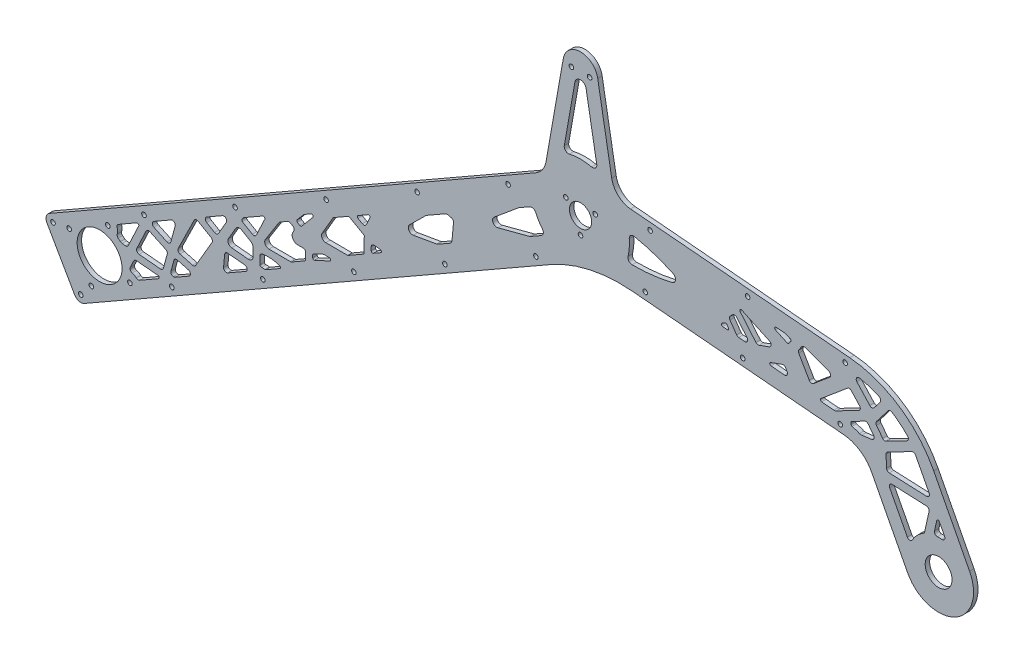
from build123d import *

# Parameters (mm, degrees)
SKETCH2_R              = 7.9375
SKETCH2_R_2            = 16.05
SKETCH2_R_3            = 1.65
SKETCH2_R_4            = 9.5885
BASE_DEPTH             = 3.175
SKETCH3_R              = 1.65
STRUT_HOLES_DEPTH      = 4.175
LIGHTENING_HOLES_DEPTH = 4.175
SKETCH7_R              = 1.65
CUT_EXTRUDE1_DEPTH     = 4.175


with BuildPart() as part:
    # Sketch2 → Base (new body)
    with BuildSketch(Plane.XY):
        with BuildLine():
            Line((-379.716809958, -188.506893436), (-32.006532147, 10.487277971))
            ThreePointArc((-32.006532147, 10.487277971), (-27.186230121, 14.879084252), (-24.685038782, 20.901319377))
            Line((-24.685038782, 20.901319377), (-12.310096913, 91.083102221))
            ThreePointArc((-12.310096913, 91.083102221), (0, 101.4125), (12.310096913, 91.083102221))
            Line((12.310096913, 91.083102221), (22.322003955, 34.302755831))
            ThreePointArc((22.322003955, 34.302755831), (26.960267136, 25.848318444), (35.786784109, 21.964558025))
            Line((35.786784109, 21.964558025), (192.586144941, 8.246391504))
            ThreePointArc((192.586144941, 8.246391504), (227.717231711, -4.10798993), (252.575276723, -31.83706486))
            Line((252.575276723, -31.83706486), (278.255270829, -81.167874559))
            ThreePointArc((278.255270829, -81.167874559), (267.623715331, -114.886860719), (233.904729171, -104.255305221))
            Line((233.904729171, -104.255305221), (208.224735064, -54.924495522))
            ThreePointArc((208.224735064, -54.924495522), (199.93872006, -45.681470545), (188.228357804, -41.563343401))
            Line((188.228357804, -41.563343401), (36.823729736, -28.317154839))
            ThreePointArc((36.823729736, -28.317154839), (6.649577682, -30.266109959), (-21.562664076, -41.144864173))
            Line((-21.562664076, -41.144864173), (-354.881400189, -231.902773674))
            ThreePointArc((-354.881400189, -231.902773674), (-358.677364619, -232.387866435), (-361.70452919, -230.046726627))
            Line((-361.70452919, -230.046726627), (-381.572857005, -195.330022437))
            ThreePointArc((-381.572857005, -195.330022437), (-382.057949767, -191.534058007), (-379.716809958, -188.506893436))
        make_face()
        Circle(SKETCH2_R, mode=Mode.SUBTRACT)
        with Locations((-343.92, -196.825)):
            Circle(SKETCH2_R_2, mode=Mode.SUBTRACT)
        with Locations((-6.5, 88.9125)):
            Circle(SKETCH2_R_3, mode=Mode.SUBTRACT)
        with Locations((6.5, 88.9125)):
            Circle(SKETCH2_R_3, mode=Mode.SUBTRACT)
        with Locations((256.08, -92.71158989)):
            Circle(SKETCH2_R_4, mode=Mode.SUBTRACT)
        with Locations((-365.631063534, -190.919094461)):
            Circle(SKETCH2_R_3, mode=Mode.SUBTRACT)
        with Locations((-338.014094461, -175.113936466)):
            Circle(SKETCH2_R_3, mode=Mode.SUBTRACT)
        with Locations((-322.208936466, -202.730905539)):
            Circle(SKETCH2_R_3, mode=Mode.SUBTRACT)
        with Locations((-349.825905539, -218.536063534)):
            Circle(SKETCH2_R_3, mode=Mode.SUBTRACT)
    extrude(amount=BASE_DEPTH)

    # Sketch3 → Strut Holes (cut, through all)
    with BuildSketch(Plane.XY.offset(3.175)):
        with Locations((-357.364941166, -227.56318565)):
            Circle(SKETCH3_R)
        with Locations((-292.27112081, -190.310070996)):
            Circle(SKETCH3_R)
        with Locations((-227.177300453, -153.056956343)):
            Circle(SKETCH3_R)
        with Locations((-162.083480097, -115.803841689)):
            Circle(SKETCH3_R)
        with Locations((-96.98965974, -78.550727035)):
            Circle(SKETCH3_R)
        with Locations((-31.895839384, -41.297612382)):
            Circle(SKETCH3_R)
        with Locations((-312.139448625, -155.593366806)):
            Circle(SKETCH3_R)
        with Locations((-377.233268981, -192.84648146)):
            Circle(SKETCH3_R)
        with Locations((-247.045628268, -118.340252152)):
            Circle(SKETCH3_R)
        with Locations((-181.951807912, -81.087137499)):
            Circle(SKETCH3_R)
        with Locations((-116.857987555, -43.834022845)):
            Circle(SKETCH3_R)
        with Locations((-51.764167199, -6.580908192)):
            Circle(SKETCH3_R)
        with Locations((46.269308527, -24.124436716)):
            Circle(SKETCH3_R)
        with Locations((116.002937393, -30.225338708)):
            Circle(SKETCH3_R)
        with Locations((185.73656626, -36.326240701)):
            Circle(SKETCH3_R)
        with Locations((189.222795969, 3.521547223)):
            Circle(SKETCH3_R)
        with Locations((119.489167103, 9.622449215)):
            Circle(SKETCH3_R)
        with Locations((49.755538237, 15.723351208)):
            Circle(SKETCH3_R)
    extrude(amount=-STRUT_HOLES_DEPTH, mode=Mode.SUBTRACT)

    # Sketch6 → Lightening Holes (cut, through all)
    with BuildSketch(Plane.XY.offset(3.175)):
        with BuildLine():
            Line((-315.269185897, -197.710920307), (-301.759255291, -189.979203363))
            ThreePointArc((-301.759255291, -189.979203363), (-301.27885272, -188.89855459), (-302.165025934, -188.115429161))
            Line((-302.165025934, -188.115429161), (-317.529091672, -186.71244549))
            ThreePointArc((-317.529091672, -186.71244549), (-318.704383169, -186.968323474), (-319.520360019, -187.852045956))
            Line((-319.520360019, -187.852045956), (-321.920665487, -192.94890269))
            ThreePointArc((-321.920665487, -192.94890269), (-322.086706026, -193.488507205), (-322.095332893, -194.053014132))
            ThreePointArc((-322.095332893, -194.053014132), (-322.08483495, -194.136958475), (-322.074659882, -194.220942566))
            ThreePointArc((-322.074659882, -194.220942566), (-321.584640098, -195.311697425), (-320.559879114, -195.927920176))
            ThreePointArc((-320.559879114, -195.927920176), (-318.977814459, -196.521247692), (-317.584009883, -197.476378529))
            ThreePointArc((-317.584009883, -197.476378529), (-316.464213346, -197.964897395), (-315.269185897, -197.710920307))
        make_face()
        with BuildLine():
            Line((-289.844978396, -183.160677107), (-279.93882887, -177.491399715))
            ThreePointArc((-279.93882887, -177.491399715), (-278.948378644, -175.502042811), (-280.407275879, -173.825692191))
            Line((-280.407275879, -173.825692191), (-288.292322007, -171.680779414))
            ThreePointArc((-288.292322007, -171.680779414), (-289.810707779, -171.874816518), (-290.747163702, -173.085682346))
            Line((-290.747163702, -173.085682346), (-292.868560549, -180.884280112))
            ThreePointArc((-292.868560549, -180.884280112), (-292.613471256, -182.502456625), (-291.234784363, -183.387209827))
            ThreePointArc((-291.234784363, -183.387209827), (-291.195764259, -183.393163574), (-291.156778347, -183.399337252))
            ThreePointArc((-291.156778347, -183.399337252), (-290.480404568, -183.392541824), (-289.844978396, -183.160677107))
        make_face()
        with BuildLine():
            Line((-225.068253149, -146.0890356), (-215.065938543, -140.36472305))
            ThreePointArc((-215.065938543, -140.36472305), (-214.567033215, -139.40324417), (-215.236329185, -138.55154524))
            ThreePointArc((-215.236329185, -138.55154524), (-221.331874052, -137.268264968), (-227.555460503, -137.531793255))
            ThreePointArc((-227.555460503, -137.531793255), (-228.747493021, -138.209832448), (-229.222550686, -139.49630005))
            Line((-229.222550686, -139.49630005), (-229.243920799, -145.124584195))
            ThreePointArc((-229.243920799, -145.124584195), (-228.903638362, -145.87990104), (-228.110599563, -146.11945299))
            ThreePointArc((-228.110599563, -146.11945299), (-226.935128796, -146.061146676), (-225.766503733, -146.200597789))
            ThreePointArc((-225.766503733, -146.200597789), (-225.407188584, -146.208593442), (-225.068253149, -146.0890356))
        make_face()
        with BuildLine():
            Line((-202.41887229, -105.511400104), (-200.686234771, -106.520529682))
            ThreePointArc((-200.686234771, -106.520529682), (-200.013042452, -106.64186894), (-199.419351845, -106.302100524))
            Line((-199.419351845, -106.302100524), (-191.360868047, -96.772094027))
            ThreePointArc((-191.360868047, -96.772094027), (-191.355986863, -95.486528074), (-192.621174572, -95.258484862))
            Line((-192.621174572, -95.258484862), (-197.478989202, -98.038606299))
            ThreePointArc((-197.478989202, -98.038606299), (-197.765321596, -98.237482482), (-198.01276947, -98.483058387))
            Line((-198.01276947, -98.483058387), (-202.679186023, -104.001587826))
            ThreePointArc((-202.679186023, -104.001587826), (-202.901047671, -104.817187109), (-202.41887229, -105.511400104))
        make_face()
        with BuildLine():
            Line((-330.425499061, -170.667183769), (-317.378257487, -163.200263197))
            ThreePointArc((-317.378257487, -163.200263197), (-316.203164595, -163.333473919), (-315.976852671, -164.494237166))
            Line((-315.976852671, -164.494237166), (-323.402158767, -180.26128093))
            ThreePointArc((-323.402158767, -180.26128093), (-324.218135617, -181.145003412), (-325.393427114, -181.400881396))
            Line((-325.393427114, -181.400881396), (-327.826064744, -181.178742873))
            ThreePointArc((-327.826064744, -181.178742873), (-328.456346912, -181.014705953), (-329.000507167, -180.656860539))
            ThreePointArc((-329.000507167, -180.656860539), (-329.788551481, -179.963737807), (-330.608754561, -179.308986045))
            ThreePointArc((-330.608754561, -179.308986045), (-331.300981929, -178.333954341), (-331.313186478, -177.138246768))
            ThreePointArc((-331.313186478, -177.138246768), (-331.014233087, -175.069882607), (-331.339196402, -173.005445087))
            ThreePointArc((-331.339196402, -173.005445087), (-331.294912573, -171.675100882), (-330.425499061, -170.667183769))
        make_face()
        with BuildLine():
            Line((-295.53330948, -171.631597975), (-298.296173769, -181.788333758))
            ThreePointArc((-298.296173769, -181.788333758), (-299.085121934, -182.906012266), (-300.407921189, -183.255077571))
            Line((-300.407921189, -183.255077571), (-315.662540801, -181.862088072))
            ThreePointArc((-315.662540801, -181.862088072), (-317.216500905, -180.86379127), (-317.290058936, -179.018262152))
            Line((-317.290058936, -179.018262152), (-310.641451377, -164.900475625))
            ThreePointArc((-310.641451377, -164.900475625), (-309.508957679, -163.870619434), (-307.979945409, -163.943195111))
            Line((-307.979945409, -163.943195111), (-296.611069066, -169.297235353))
            ThreePointArc((-296.611069066, -169.297235353), (-295.647370018, -170.26828046), (-295.53330948, -171.631597975))
        make_face()
        with BuildLine():
            Line((-292.778723285, -149.121979529), (-305.215642876, -156.239613568))
            ThreePointArc((-305.215642876, -156.239613568), (-306.220639762, -158.055100377), (-305.074339213, -159.784842018))
            Line((-305.074339213, -159.784842018), (-295.766029178, -164.168482495))
            ThreePointArc((-295.766029178, -164.168482495), (-294.075568316, -164.17490103), (-292.984044137, -162.884058635))
            Line((-292.984044137, -162.884058635), (-289.85543458, -151.38278412))
            ThreePointArc((-289.85543458, -151.38278412), (-290.561768266, -149.275742292), (-292.778723285, -149.121979529))
        make_face()
        with BuildLine():
            Line((-286.412158457, -167.010536912), (-277.477694151, -169.440915421))
            ThreePointArc((-277.477694151, -169.440915421), (-276.194379154, -169.361694864), (-275.224483334, -168.5176123))
            Line((-275.224483334, -168.5176123), (-263.487039881, -148.364863469))
            ThreePointArc((-263.487039881, -148.364863469), (-263.281478176, -146.847994939), (-264.208712124, -145.63005284))
            Line((-264.208712124, -145.63005284), (-273.491108909, -140.223762697))
            ThreePointArc((-273.491108909, -140.223762697), (-275.075155334, -140.037188202), (-276.291924346, -141.06844292))
            Line((-276.291924346, -141.06844292), (-287.68143532, -164.197103385))
            ThreePointArc((-287.68143532, -164.197103385), (-287.710247586, -165.903135064), (-286.412158457, -167.010536912))
        make_face()
        with BuildLine():
            Line((-267.326941544, -134.555955625), (-255.981699002, -128.063087041))
            ThreePointArc((-255.981699002, -128.063087041), (-253.568709634, -128.390088491), (-253.260041176, -130.805491443))
            Line((-253.260041176, -130.805491443), (-258.957478514, -140.587777008))
            ThreePointArc((-258.957478514, -140.587777008), (-260.175420613, -141.515010956), (-261.692289142, -141.309449251))
            Line((-261.692289142, -141.309449251), (-267.340094346, -138.02003227))
            ThreePointArc((-267.340094346, -138.02003227), (-268.333510737, -136.284197061), (-267.326941544, -134.555955625))
        make_face()
        with BuildLine():
            Line((-255.261313261, -159.742391016), (-254.488576255, -151.280152708))
            ThreePointArc((-254.488576255, -151.280152708), (-253.776611846, -149.925068788), (-252.314987955, -149.470314621))
            Line((-252.314987955, -149.470314621), (-240.229659184, -150.573897437))
            ThreePointArc((-240.229659184, -150.573897437), (-238.457312757, -152.140148294), (-239.418117899, -154.30144584))
            Line((-239.418117899, -154.30144584), (-252.276183677, -161.660101332))
            ThreePointArc((-252.276183677, -161.660101332), (-254.350596062, -161.606956723), (-255.261313261, -159.742391016))
        make_face()
        with BuildLine():
            Line((-246.540160509, -131.189393308), (-251.794794147, -140.211401578))
            ThreePointArc((-251.794794147, -140.211401578), (-251.868704934, -143.096387582), (-249.475244653, -144.708825158))
            Line((-249.475244653, -144.708825158), (-237.508018237, -145.801623349))
            ThreePointArc((-237.508018237, -145.801623349), (-235.21684764, -145.033565045), (-234.235227202, -142.825444219))
            Line((-234.235227202, -142.825444219), (-234.211718457, -136.633904573))
            ThreePointArc((-234.211718457, -136.633904573), (-234.607944018, -135.132389326), (-235.701843043, -134.030151758))
            Line((-235.701843043, -134.030151758), (-242.437944567, -130.106884943))
            ThreePointArc((-242.437944567, -130.106884943), (-244.713247361, -129.798542386), (-246.540160509, -131.189393308))
        make_face()
        with BuildLine():
            Line((-241.753564235, -124.719255848), (-234.63976684, -128.862501783))
            ThreePointArc((-234.63976684, -128.862501783), (-233.039032694, -129.043963991), (-231.823804406, -127.986373074))
            Line((-231.823804406, -127.986373074), (-225.796901327, -115.1887263))
            ThreePointArc((-225.796901327, -115.1887263), (-226.023213251, -114.027963054), (-227.198306143, -113.894752332))
            Line((-227.198306143, -113.894752332), (-240.486863137, -121.499777426))
            ThreePointArc((-240.486863137, -121.499777426), (-240.868014227, -121.782834524), (-241.171709307, -122.147754751))
            ThreePointArc((-241.171709307, -122.147754751), (-241.549582312, -122.675396768), (-241.974698217, -123.165774758))
            ThreePointArc((-241.974698217, -123.165774758), (-242.240299662, -123.996061899), (-241.753564235, -124.719255848))
        make_face()
        with BuildLine():
            Line((-215.668807888, -112.174898455), (-225.379976009, -127.585503674))
            ThreePointArc((-225.379976009, -127.585503674), (-225.4712487, -130.629365716), (-222.853276851, -132.184888211))
            Line((-222.853276851, -132.184888211), (-207.454371398, -132.243356535))
            ThreePointArc((-207.454371398, -132.243356535), (-206.936478287, -132.177174092), (-206.453361233, -131.979206161))
            Line((-206.453361233, -131.979206161), (-197.505650544, -126.858442157))
            ThreePointArc((-197.505650544, -126.858442157), (-196.770825499, -126.12917614), (-196.499081351, -125.130200721))
            Line((-196.499081351, -125.130200721), (-196.484480993, -121.28487852))
            ThreePointArc((-196.484480993, -121.28487852), (-197.064893599, -119.868450986), (-198.476872802, -119.277299162))
            Line((-198.476872802, -119.277299162), (-202.260748213, -119.262932112))
            ThreePointArc((-202.260748213, -119.262932112), (-205.751377346, -117.188902119), (-205.629680425, -113.130419396))
            Line((-205.629680425, -113.130419396), (-205.026921593, -112.173904352))
            ThreePointArc((-205.026921593, -112.173904352), (-204.776566908, -110.63116148), (-205.712412279, -109.379392142))
            Line((-205.712412279, -109.379392142), (-207.46181523, -108.360497976))
            ThreePointArc((-207.46181523, -108.360497976), (-208.460790649, -108.088753828), (-209.461800813, -108.352904202))
            Line((-209.461800813, -108.352904202), (-214.9701644, -111.50533402))
            ThreePointArc((-214.9701644, -111.50533402), (-215.360592232, -111.79722492), (-215.668807888, -112.174898455))
        make_face()
        with BuildLine():
            Line((-191.479772218, -120.054212502), (-191.486581073, -121.847472571))
            ThreePointArc((-191.486581073, -121.847472571), (-191.027086278, -122.692614758), (-190.067414214, -122.759175345))
            Line((-190.067414214, -122.759175345), (-179.245533818, -117.762785652))
            ThreePointArc((-179.245533818, -117.762785652), (-178.687597118, -116.642148596), (-179.660910998, -115.854886972))
            Line((-179.660910998, -115.854886972), (-183.284876561, -115.841127086))
            ThreePointArc((-183.284876561, -115.841127086), (-183.717932672, -115.886891136), (-184.13081847, -116.025300894))
            Line((-184.13081847, -116.025300894), (-190.898953493, -119.150103501))
            ThreePointArc((-190.898953493, -119.150103501), (-191.321124727, -119.517511391), (-191.479772218, -120.054212502))
        make_face()
        with BuildLine():
            Line((-166.401123038, -107.905175585), (-182.204856698, -107.845170163))
            ThreePointArc((-182.204856698, -107.845170163), (-184.797218852, -106.335316373), (-184.785828191, -103.335337998))
            Line((-184.785828191, -103.335337998), (-176.831995141, -89.678905885))
            Line((-176.831995141, -89.678905885), (-165.638950905, -83.273140207))
            Line((-165.638950905, -83.273140207), (-154.64049223, -89.678905885))
            Line((-154.64049223, -89.678905885), (-154.684235374, -101.199614947))
            Line((-154.684235374, -101.199614947), (-166.401123038, -107.905175585))
        make_face()
        with BuildLine():
            Line((-149.666734346, -96.599830521), (-149.657550536, -94.181074309))
            ThreePointArc((-149.657550536, -94.181074309), (-149.003136911, -92.708993759), (-147.475689846, -92.196954889))
            Line((-147.475689846, -92.196954889), (-143.284670701, -92.579661624))
            ThreePointArc((-143.284670701, -92.579661624), (-142.398497488, -93.362787052), (-142.878900059, -94.443435825))
            Line((-142.878900059, -94.443435825), (-148.170033359, -97.471545013))
            ThreePointArc((-148.170033359, -97.471545013), (-149.170026151, -97.467748126), (-149.666734346, -96.599830521))
        make_face()
        with BuildLine():
            Line((-159.124748889, -79.545070273), (-152.013980011, -75.475585845))
            ThreePointArc((-152.013980011, -75.475585845), (-150.838887119, -75.608796567), (-150.612575195, -76.769559813))
            Line((-150.612575195, -76.769559813), (-153.182146906, -82.225839878))
            ThreePointArc((-153.182146906, -82.225839878), (-154.397375194, -83.283430795), (-155.99810934, -83.101968586))
            Line((-155.99810934, -83.101968586), (-159.13132529, -81.277108596))
            ThreePointArc((-159.13132529, -81.277108596), (-159.628033486, -80.409190991), (-159.124748889, -79.545070273))
        make_face()
        with BuildLine():
            Line((-90.819864813, -49.698540482), (-91.896421351, -61.487904644))
            ThreePointArc((-91.896421351, -61.487904644), (-92.359955239, -62.836585977), (-93.393866555, -63.818844799))
            Line((-93.393866555, -63.818844799), (-101.994338017, -68.740884214))
            ThreePointArc((-101.994338017, -68.740884214), (-102.469113289, -68.960084777), (-102.974739436, -69.09351133))
            Line((-102.974739436, -69.09351133), (-119.629879497, -71.965101226))
            ThreePointArc((-119.629879497, -71.965101226), (-122.805875604, -70.383853511), (-122.252853304, -66.87936183))
            Line((-122.252853304, -66.87936183), (-110.681116507, -55.395166432))
            ThreePointArc((-110.681116507, -55.395166432), (-110.385100172, -55.137548838), (-110.057990454, -54.920773084))
            Line((-110.057990454, -54.920773084), (-96.724691463, -47.290142199))
            ThreePointArc((-96.724691463, -47.290142199), (-95.614849419, -46.918095089), (-94.447112805, -46.999086542))
            Line((-94.447112805, -46.999086542), (-92.286608626, -47.586793062))
            ThreePointArc((-92.286608626, -47.586793062), (-91.168930118, -48.375741228), (-90.819864813, -49.698540482))
        make_face()
        with BuildLine():
            Line((-28.096781534, -26.449402024), (-35.825401618, -30.87248195))
            ThreePointArc((-35.825401618, -30.87248195), (-36.178007781, -31.044706772), (-36.550077199, -31.169433846))
            Line((-36.550077199, -31.169433846), (-59.133973609, -37.128958431))
            ThreePointArc((-59.133973609, -37.128958431), (-62.565695554, -35.603385935), (-61.819045791, -31.92281518))
            Line((-61.819045791, -31.92281518), (-44.317223042, -17.349924163))
            ThreePointArc((-44.317223042, -17.349924163), (-44.108986088, -17.191390869), (-43.887724451, -17.051609889))
            Line((-43.887724451, -17.051609889), (-36.274597881, -12.694626761))
            ThreePointArc((-36.274597881, -12.694626761), (-33.845543285, -12.449097133), (-32.038330666, -14.090612767))
            ThreePointArc((-32.038330666, -14.090612767), (-29.904900702, -18.185073934), (-27.251097742, -21.963097956))
            ThreePointArc((-27.251097742, -21.963097956), (-26.638826778, -24.401372335), (-28.096781534, -26.449402024))
        make_face()
        with BuildLine():
            Line((-11.599665343, 37.524455033), (-3.986146646, 80.702865203))
            ThreePointArc((-3.986146646, 80.702865203), (0, 84.047639383), (3.986146646, 80.702865203))
            Line((3.986146646, 80.702865203), (11.599665343, 37.524455033))
            ThreePointArc((11.599665343, 37.524455033), (10.707449692, 34.824680589), (7.962722972, 34.082180723))
            ThreePointArc((7.962722972, 34.082180723), (0, 35), (-7.962722972, 34.082180723))
            ThreePointArc((-7.962722972, 34.082180723), (-10.707449692, 34.824680589), (-11.599665343, 37.524455033))
        make_face()
        with BuildLine():
            Line((246.075987756, -72.913561708), (249.254007124, -58.57844272))
            ThreePointArc((249.254007124, -58.57844272), (248.888121791, -56.928040634), (247.388653885, -56.147467049))
            Line((247.388653885, -56.147467049), (222.962162816, -55.080983417))
            ThreePointArc((222.962162816, -55.080983417), (221.188141149, -56.004480644), (221.100902375, -58.002577087))
            Line((221.100902375, -58.002577087), (233.735290203, -82.273010289))
            ThreePointArc((233.735290203, -82.273010289), (235.484637714, -83.349360854), (237.260008731, -82.316498325))
            ThreePointArc((237.260008731, -82.316498325), (240.657318696, -77.731906936), (245.140979083, -74.202461834))
            ThreePointArc((245.140979083, -74.202461834), (245.742284649, -73.655075389), (246.075987756, -72.913561708))
        make_face()
        with BuildLine():
            Line((253.133679234, -68.799730633), (254.751992566, -61.499990928))
            ThreePointArc((254.751992566, -61.499990928), (255.597762381, -60.72498568), (256.615299406, -61.254681929))
            Line((256.615299406, -61.254681929), (260.345615198, -68.420551892))
            ThreePointArc((260.345615198, -68.420551892), (260.223925452, -70.470902803), (258.359543018, -71.332775993))
            ThreePointArc((258.359543018, -71.332775993), (256.767087179, -71.222571503), (255.170843908, -71.230820928))
            ThreePointArc((255.170843908, -71.230820928), (253.553325039, -70.51716267), (253.133679234, -68.799730633))
        make_face()
        with BuildLine():
            Line((249.310771487, -47.22281435), (239.59747458, -28.563744597))
            ThreePointArc((239.59747458, -28.563744597), (238.424864512, -27.579807922), (236.899955687, -27.713220157))
            Line((236.899955687, -27.713220157), (219.565597936, -36.736915644))
            ThreePointArc((219.565597936, -36.736915644), (218.757044355, -37.510937311), (218.490998719, -38.598176086))
            Line((218.490998719, -38.598176086), (218.860832904, -47.068771554))
            ThreePointArc((218.860832904, -47.068771554), (219.444715785, -48.395746342), (220.771690573, -48.979629223))
            Line((220.771690573, -48.979629223), (247.449511046, -50.144408019))
            ThreePointArc((247.449511046, -50.144408019), (249.223532712, -49.220910793), (249.310771487, -47.22281435))
        make_face()
        with BuildLine():
            Line((233.413458883, -22.763883833), (218.618137266, -30.46584077))
            ThreePointArc((218.618137266, -30.46584077), (217.261760811, -30.644411118), (216.107933359, -29.909341962))
            Line((216.107933359, -29.909341962), (211.671799483, -24.128059737))
            ThreePointArc((211.671799483, -24.128059737), (211.258506163, -22.910536879), (211.671799483, -21.693014021))
            Line((211.671799483, -21.693014021), (220.007167815, -10.830150518))
            ThreePointArc((220.007167815, -10.830150518), (221.257760997, -10.076118732), (222.687548657, -10.3731953))
            ThreePointArc((222.687548657, -10.3731953), (228.553817552, -14.676513168), (233.918900039, -19.590528361))
            ThreePointArc((233.918900039, -19.590528361), (234.465065341, -21.304449895), (233.413458883, -22.763883833))
        make_face()
        with BuildLine():
            Line((209.61657846, -31.305721344), (205.746256457, -26.261819508))
            ThreePointArc((205.746256457, -26.261819508), (204.592429004, -25.526750352), (203.23605255, -25.7053207))
            Line((203.23605255, -25.7053207), (194.010059092, -30.508068903))
            ThreePointArc((194.010059092, -30.508068903), (193.616895834, -30.876306478), (193.471807705, -31.395079736))
            Line((193.471807705, -31.395079736), (193.471807705, -32.496691451))
            ThreePointArc((193.471807705, -32.496691451), (193.684204256, -33.112873898), (194.23116932, -33.467306291))
            ThreePointArc((194.23116932, -33.467306291), (196.89746606, -34.245224393), (199.491371204, -35.238175037))
            ThreePointArc((199.491371204, -35.238175037), (200.2654041, -35.454155852), (201.069000396, -35.456918226))
            Line((201.069000396, -35.456918226), (208.290924164, -34.506133925))
            ThreePointArc((208.290924164, -34.506133925), (209.877630844, -33.288611067), (209.61657846, -31.305721344))
        make_face()
        with BuildLine():
            Line((214.303083467, -8.407780179), (209.957683706, -14.070815403))
            ThreePointArc((209.957683706, -14.070815403), (208.4582158, -14.851388988), (206.896422352, -14.20447296))
            Line((206.896422352, -14.20447296), (197.688681904, -4.155987535))
            ThreePointArc((197.688681904, -4.155987535), (197.423723958, -1.817844179), (199.566737265, -0.845933158))
            ThreePointArc((199.566737265, -0.845933158), (206.676023639, -2.722269436), (213.536897173, -5.366320289))
            ThreePointArc((213.536897173, -5.366320289), (214.655785228, -6.701693203), (214.303083467, -8.407780179))
        make_face()
        with BuildLine():
            Line((193.681402215, -11.624307007), (199.545514004, -18.023862053))
            ThreePointArc((199.545514004, -18.023862053), (200.040574836, -19.722338824), (198.994456557, -21.149064135))
            Line((198.994456557, -21.149064135), (182.807531418, -29.575444012))
            ThreePointArc((182.807531418, -29.575444012), (182.007556544, -29.856767353), (181.16081835, -29.902995606))
            Line((181.16081835, -29.902995606), (172.48260155, -29.143750017))
            ThreePointArc((172.48260155, -29.143750017), (171.616040342, -28.448261118), (171.926969683, -27.381510875))
            Line((171.926969683, -27.381510875), (190.921272322, -11.443398536))
            ThreePointArc((190.921272322, -11.443398536), (192.3376538, -10.979769576), (193.681402215, -11.624307007))
        make_face()
        with BuildLine():
            Line((178.199205815, -11.022517891), (166.591800736, -20.762287211))
            ThreePointArc((166.591800736, -20.762287211), (164.958929162, -21.199813831), (163.574174709, -20.230198325))
            Line((163.574174709, -20.230198325), (156.047951006, -7.194396481))
            ThreePointArc((156.047951006, -7.194396481), (155.78190537, -6.107157706), (156.141697725, -5.047243608))
            Line((156.141697725, -5.047243608), (158.18845934, -2.124165087))
            ThreePointArc((158.18845934, -2.124165087), (159.22535183, -1.363884058), (160.510803716, -1.391932718))
            Line((160.510803716, -1.391932718), (177.597670882, -7.611043763))
            ThreePointArc((177.597670882, -7.611043763), (178.883246101, -9.143132649), (178.199205815, -11.022517891))
        make_face()
        with BuildLine():
            Line((146.644806866, -20.907673079), (147.746965574, -22.816667961))
            ThreePointArc((147.746965574, -22.816667961), (147.701697658, -24.891267177), (145.840603281, -25.809057357))
            Line((145.840603281, -25.809057357), (136.229987031, -24.968237386))
            ThreePointArc((136.229987031, -24.968237386), (135.325697913, -24.10256888), (135.975122631, -23.032350067))
            Line((135.975122631, -23.032350067), (144.228715771, -20.028287838))
            ThreePointArc((144.228715771, -20.028287838), (145.596796345, -20.028287838), (146.644806866, -20.907673079))
        make_face()
        with BuildLine():
            Line((134.974345297, -13.819003275), (127.671845659, -16.476895779))
            ThreePointArc((127.671845659, -16.476895779), (126.470167282, -16.52936219), (125.455716486, -15.883085757))
            Line((125.455716486, -15.883085757), (114.198527576, -2.46729043))
            ThreePointArc((114.198527576, -2.46729043), (114.171218678, -1.215741392), (115.387190281, -0.918195034))
            Line((115.387190281, -0.918195034), (135.135541534, -10.127002459))
            ThreePointArc((135.135541534, -10.127002459), (136.288401454, -12.026856808), (134.974345297, -13.819003275))
        make_face()
        with BuildLine():
            Line((139.430597275, -1.096040654), (147.83182135, -5.013595778))
            ThreePointArc((147.83182135, -5.013595778), (148.513258657, -5.073213817), (149.073591656, -4.680864427))
            Line((149.073591656, -4.680864427), (150.425898479, -2.749570135))
            ThreePointArc((150.425898479, -2.749570135), (150.560463385, -1.875287899), (149.948766578, -1.236301077))
            Line((149.948766578, -1.236301077), (146.098496258, 0.165082713))
            ThreePointArc((146.098496258, 0.165082713), (145.72175467, 0.274892872), (145.333903056, 0.334588945))
            Line((145.333903056, 0.334588945), (139.940371279, 0.806461832))
            ThreePointArc((139.940371279, 0.806461832), (138.88728971, 0.069086179), (139.430597275, -1.096040654))
        make_face()
        with BuildLine():
            Line((111.660494937, -7.221200049), (119.04545342, -16.022250853))
            ThreePointArc((119.04545342, -16.022250853), (119.2873862, -18.231323299), (117.339053048, -19.300215468))
            Line((117.339053048, -19.300215468), (113.116226003, -18.930765974))
            ThreePointArc((113.116226003, -18.930765974), (112.290537488, -18.670427385), (111.6522334, -18.08552945))
            Line((111.6522334, -18.08552945), (106.877510971, -11.266519132))
            ThreePointArc((106.877510971, -11.266519132), (106.523425664, -9.945054773), (107.101601497, -8.705152697))
            Line((107.101601497, -8.705152697), (108.714192488, -7.092561706))
            ThreePointArc((108.714192488, -7.092561706), (110.215644825, -6.508678825), (111.660494937, -7.221200049))
        make_face()
        with BuildLine():
            Line((104.703890017, -15.136053881), (105.75536165, -16.637710998))
            ThreePointArc((105.75536165, -16.637710998), (105.80223501, -17.711287434), (104.849053863, -18.207482132))
            Line((104.849053863, -18.207482132), (101.67727128, -17.929987113))
            ThreePointArc((101.67727128, -17.929987113), (100.788131016, -17.150232029), (101.264427023, -16.067767011))
            Line((101.264427023, -16.067767011), (103.384737973, -14.843604914))
            ThreePointArc((103.384737973, -14.843604914), (104.101177587, -14.73333431), (104.703890017, -15.136053881))
        make_face()
        with BuildLine():
            ThreePointArc((34.863622447, 3.086718303), (34.900341082, -2.63935454), (34.002891304, -8.294780463))
            ThreePointArc((34.002891304, -8.294780463), (34.552114447, -10.851108963), (36.89804352, -12.005699039))
            ThreePointArc((36.89804352, -12.005699039), (51.290024205, -11.233136631), (65.485577957, -8.740705208))
            ThreePointArc((65.485577957, -8.740705208), (67.910545504, -5.973310403), (66.09771963, -2.77134164))
            ThreePointArc((66.09771963, -2.77134164), (52.541526947, 2.603547383), (38.433463256, 6.29439159))
            ThreePointArc((38.433463256, 6.29439159), (35.846829531, 5.582787002), (34.863622447, 3.086718303))
        make_face()
    extrude(amount=-LIGHTENING_HOLES_DEPTH, mode=Mode.SUBTRACT)

    # Sketch7 → Cut-Extrude1 (cut, through all)
    with BuildSketch(Plane.XY.offset(3.175)):
        with Locations((-10.5, 6.062177826)):
            Circle(SKETCH7_R)
        with Locations((10.5, 6.062177826)):
            Circle(SKETCH7_R)
        with Locations((0, -12.124355653)):
            Circle(SKETCH7_R)
    extrude(amount=-CUT_EXTRUDE1_DEPTH, mode=Mode.SUBTRACT)


solid = part.part
